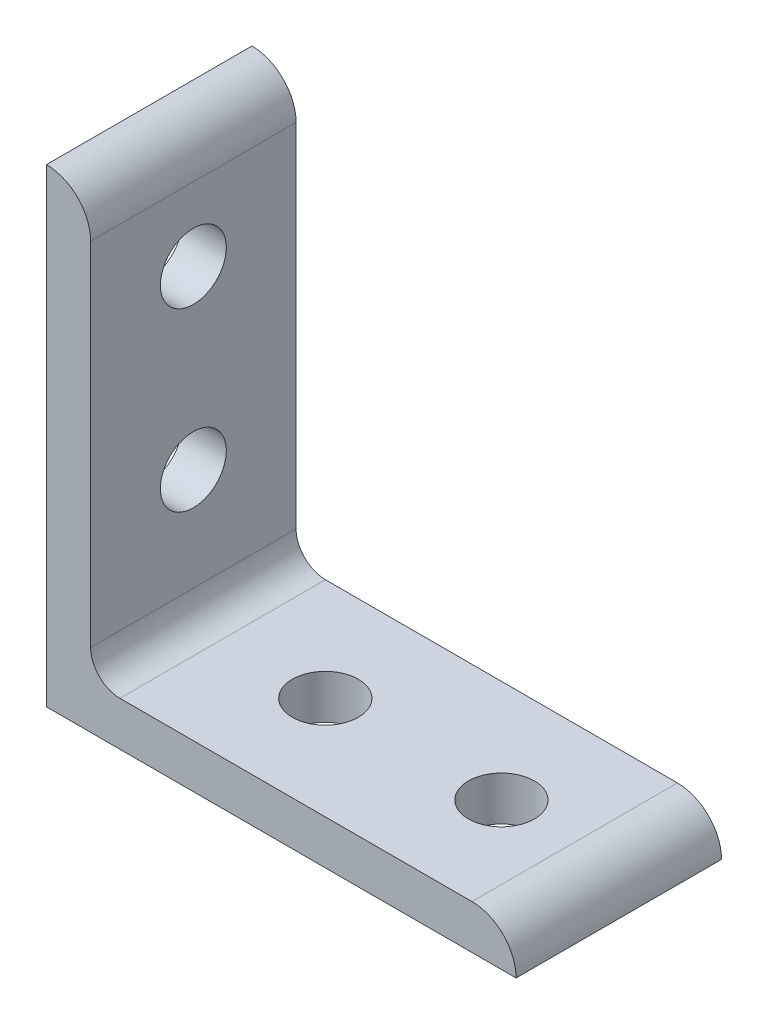
from build123d import *

# Parameters (mm, degrees)
BOSS_EXTRUDE1_DEPTH = 11.1125
SKETCH2_R           = 3.5687
CUT_EXTRUDE1_DEPTH  = 51.8
SKETCH3_R           = 3.5687
CUT_EXTRUDE2_DEPTH  = 51.8


with BuildPart() as part:
    # Sketch1 → Boss-Extrude1 (new body, symmetric)
    with BuildSketch(Plane.XY):
        with BuildLine():
            Line((0, 0), (0, 50.8))
            ThreePointArc((0, 50.8), (3.376576302, 49.401376302), (4.7752, 46.0248))
            Line((4.7752, 46.0248), (4.7752, 7.9502))
            ThreePointArc((4.7752, 7.9502), (5.70513597, 5.70513597), (7.9502, 4.7752))
            Line((7.9502, 4.7752), (46.0248, 4.7752))
            ThreePointArc((46.0248, 4.7752), (49.401376302, 3.376576302), (50.8, 0))
            Line((50.8, 0), (0, 0))
        make_face()
    extrude(amount=BOSS_EXTRUDE1_DEPTH, both=True)

    # Sketch2 → Cut-Extrude1 (cut, through all)
    with BuildSketch(Plane(origin=(0, 0, 0), x_dir=(1, 0, 0), z_dir=(0, 1, 0))):
        with Locations((19.05, 0)):
            Circle(SKETCH2_R)
        with Locations((38.1, 0)):
            Circle(SKETCH2_R)
    extrude(amount=CUT_EXTRUDE1_DEPTH, mode=Mode.SUBTRACT)

    # Sketch3 → Cut-Extrude2 (cut, through all)
    with BuildSketch(Plane(origin=(0, 0, 0), x_dir=(0, 0, -1), z_dir=(1, 0, 0))):
        with Locations((0, 19.05)):
            Circle(SKETCH3_R)
        with Locations((0, 38.1)):
            Circle(SKETCH3_R)
    extrude(amount=CUT_EXTRUDE2_DEPTH, mode=Mode.SUBTRACT)


solid = part.part
